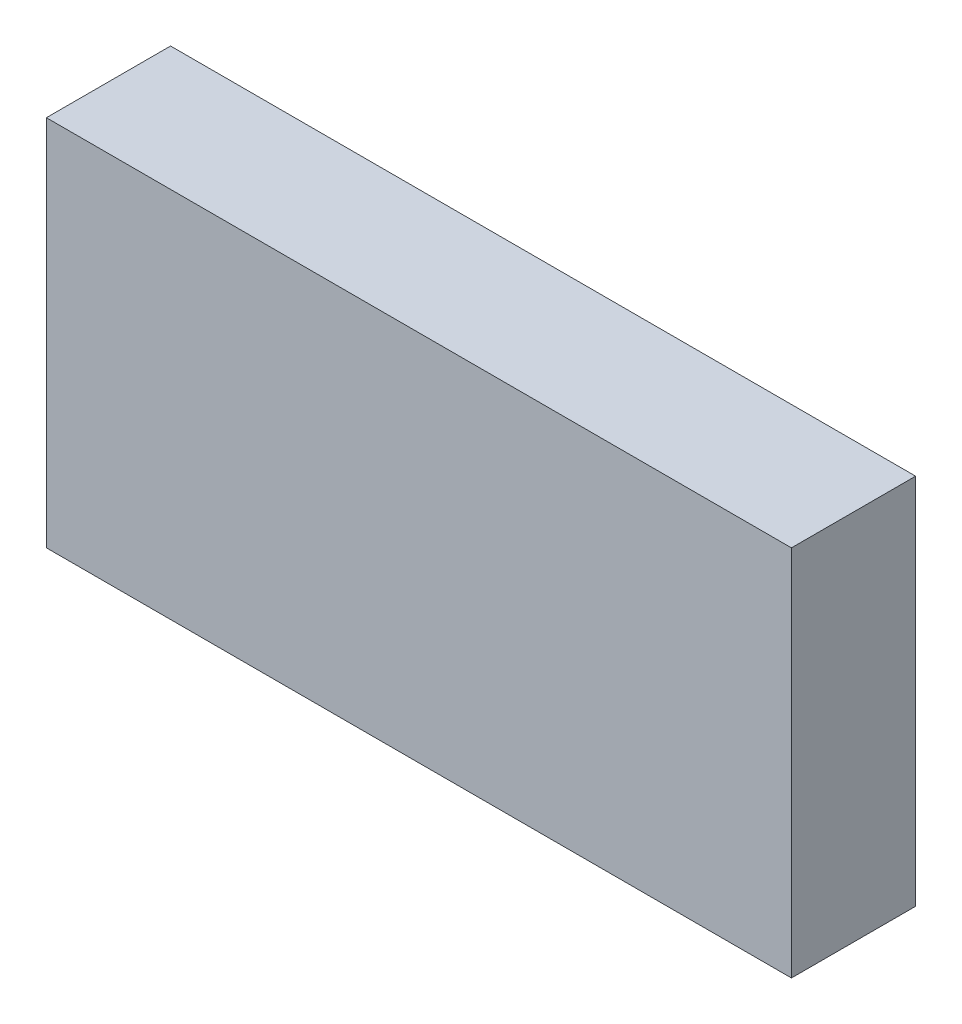
from build123d import *

# Parameters (mm, degrees)
SKETCH1_W           = 30
SKETCH1_H           = 15
BOSS_EXTRUDE1_DEPTH = 5


with BuildPart() as part:
    # Sketch1 → Boss-Extrude1 (new body)
    with BuildSketch(Plane.XY):
        with Locations((15, 7.5)):
            Rectangle(SKETCH1_W, SKETCH1_H)
    extrude(amount=BOSS_EXTRUDE1_DEPTH)


solid = part.part
